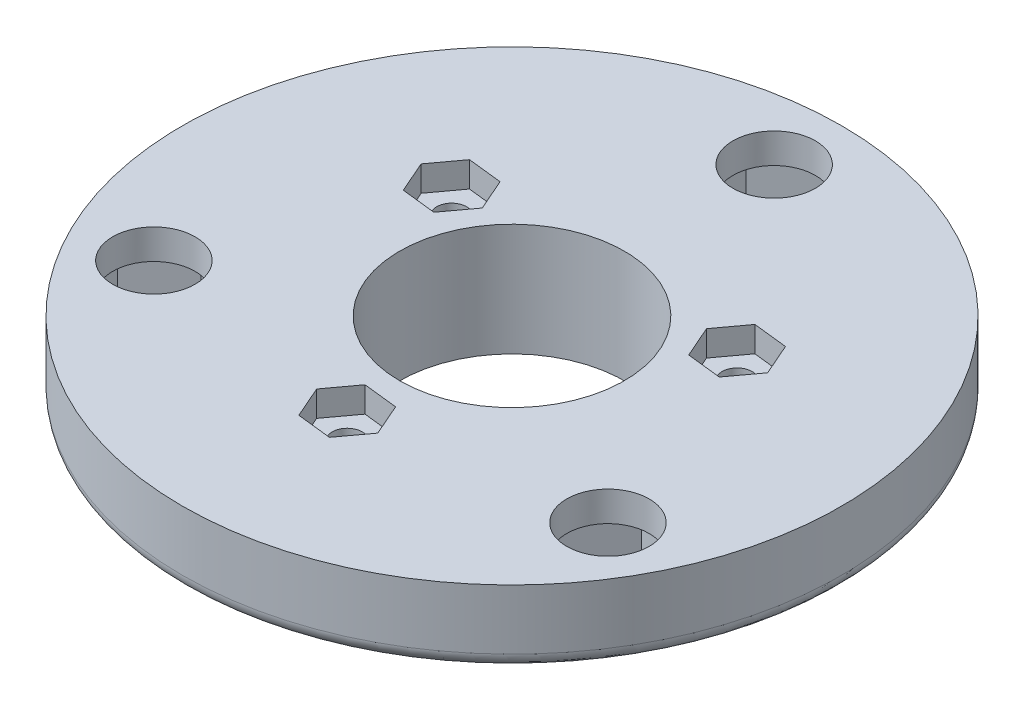
from build123d import *

# Parameters (mm, degrees)
SKETCH1_R           = 22
SKETCH1_R_2         = 2.75
SKETCH1_R_3         = 7.5
SKETCH1_R_4         = 1
BOSS_EXTRUDE1_DEPTH = 7.5
SKETCH2_R           = 22
SKETCH2_R_2         = 13.5
CUT_EXTRUDE1_DEPTH  = 2.5
FILLET2_R           = 1
CUT_EXTRUDE2_DEPTH  = 1.7
CUT_EXTRUDE3_DEPTH  = 3


with BuildPart() as part:
    # Sketch1 → Boss-Extrude1 (new body)
    with BuildSketch(Plane(origin=(0, 0, 0), x_dir=(1, 0, 0), z_dir=(0, 1, 0))):
        Circle(SKETCH1_R)
        with Locations((0, 17.5)):
            Circle(SKETCH1_R_2, mode=Mode.SUBTRACT)
        with Locations((-15.155444566, -8.75)):
            Circle(SKETCH1_R_2, mode=Mode.SUBTRACT)
        with Locations((15.155444566, -8.75)):
            Circle(SKETCH1_R_2, mode=Mode.SUBTRACT)
        Circle(SKETCH1_R_3, mode=Mode.SUBTRACT)
        with Locations((-9.526279442, 5.5)):
            Circle(SKETCH1_R_4, mode=Mode.SUBTRACT)
        with Locations((9.526279442, 5.5)):
            Circle(SKETCH1_R_4, mode=Mode.SUBTRACT)
        with Locations((0, -11)):
            Circle(SKETCH1_R_4, mode=Mode.SUBTRACT)
    extrude(amount=BOSS_EXTRUDE1_DEPTH)

    # Sketch2 → Cut-Extrude1 (cut)
    with BuildSketch(Plane.XZ):
        Circle(SKETCH2_R)
        Circle(SKETCH2_R_2, mode=Mode.SUBTRACT)
    extrude(amount=-CUT_EXTRUDE1_DEPTH, mode=Mode.SUBTRACT)

    # Fillet2
    fillet2_edges = [part.edges().sort_by_distance(p)[0] for p in [
        (-22, 2.5, 0),
    ]]
    fillet(fillet2_edges, radius=FILLET2_R)

    # Sketch4 → Cut-Extrude2 (cut)
    with BuildSketch(Plane(origin=(0, 7.5, 0), x_dir=(1, 0, 0), z_dir=(0, 1, 0))):
        Polygon((8.157191191, 3.640179929), (10.452386744, 3.384424759), (11.821474995, 5.24424483), (10.895367692, 7.359820071), (8.600172139, 7.615575241), (7.231083889, 5.75575517), align=None)
        Polygon((-1.369088251, -12.859820071), (0.926107302, -13.115575241), (2.295195553, -11.25575517), (1.369088251, -9.140179929), (-0.926107302, -8.884424759), (-2.295195553, -10.74424483), align=None)
        Polygon((-10.895367692, 3.640179929), (-8.600172139, 3.384424759), (-7.231083889, 5.24424483), (-8.157191191, 7.359820071), (-10.452386744, 7.615575241), (-11.821474995, 5.75575517), align=None)
    extrude(amount=-CUT_EXTRUDE2_DEPTH, mode=Mode.SUBTRACT)

    # Sketch5 → Cut-Extrude3 (cut)
    with BuildSketch(Plane.XZ.offset(-2.5)):
        Polygon((12.687667108, 11.82566379), (11.257952861, 8.150673926), (13.725730319, 5.075010135), (17.623222024, 5.67433621), (19.052936271, 9.349326074), (16.585158813, 12.424989865), align=None)
        Polygon((-18.145928854, 11.320337927), (-18.876664651, 7.445333601), (-15.886180363, 4.874995674), (-12.164960279, 6.179662073), (-11.434224481, 10.054666399), (-14.424708769, 12.625004326), align=None)
        Polygon((-3.240770937, -15.253438836), (-3.565964508, -19.183309377), (-0.325193571, -21.429870542), (3.240770937, -19.746561164), (3.565964508, -15.816690623), (0.325193571, -13.570129458), align=None)
    extrude(amount=-CUT_EXTRUDE3_DEPTH, mode=Mode.SUBTRACT)


solid = part.part
